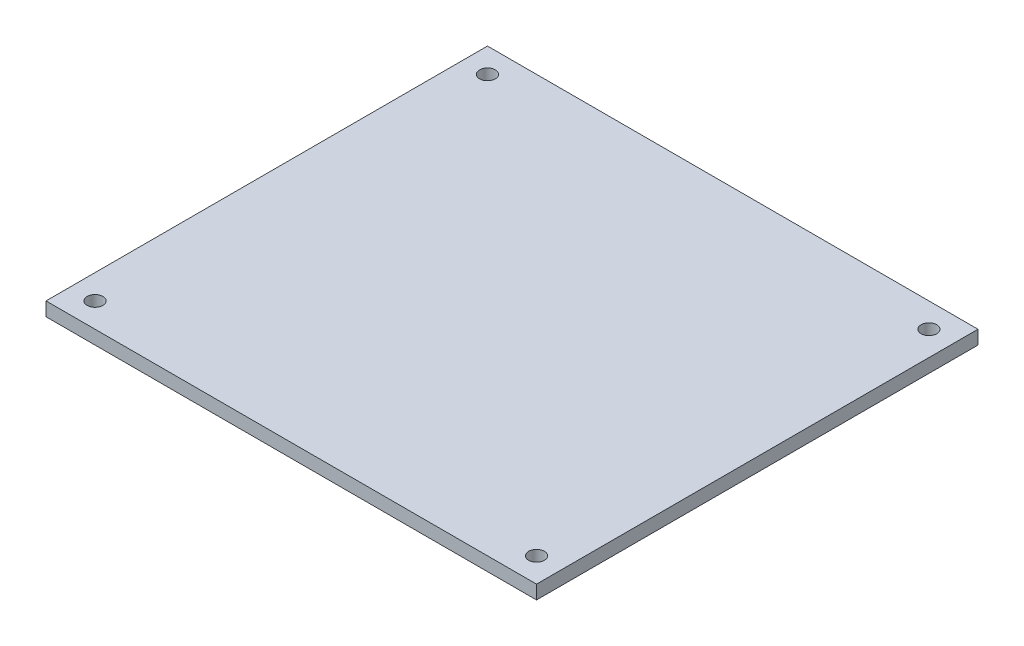
from build123d import *

# Parameters (mm, degrees)
SKETCH_1_W      = 100
SKETCH_1_H      = 90
SKETCH_1_R      = 1.6
EXTRUDE_1_DEPTH = 2.8


with BuildPart() as part:
    # 草图1 → 凸台-拉伸1 (new body)
    with BuildSketch(Plane(origin=(0, 0, 0), x_dir=(1, 0, 0), z_dir=(0, 1, 0))):
        with Locations((50, 45)):
            Rectangle(SKETCH_1_W, SKETCH_1_H)
        with Locations((5, 85)):
            Circle(SKETCH_1_R, mode=Mode.SUBTRACT)
        with Locations((95, 85)):
            Circle(SKETCH_1_R, mode=Mode.SUBTRACT)
        with Locations((95, 5)):
            Circle(SKETCH_1_R, mode=Mode.SUBTRACT)
        with Locations((5, 5)):
            Circle(SKETCH_1_R, mode=Mode.SUBTRACT)
    extrude(amount=EXTRUDE_1_DEPTH)


solid = part.part
